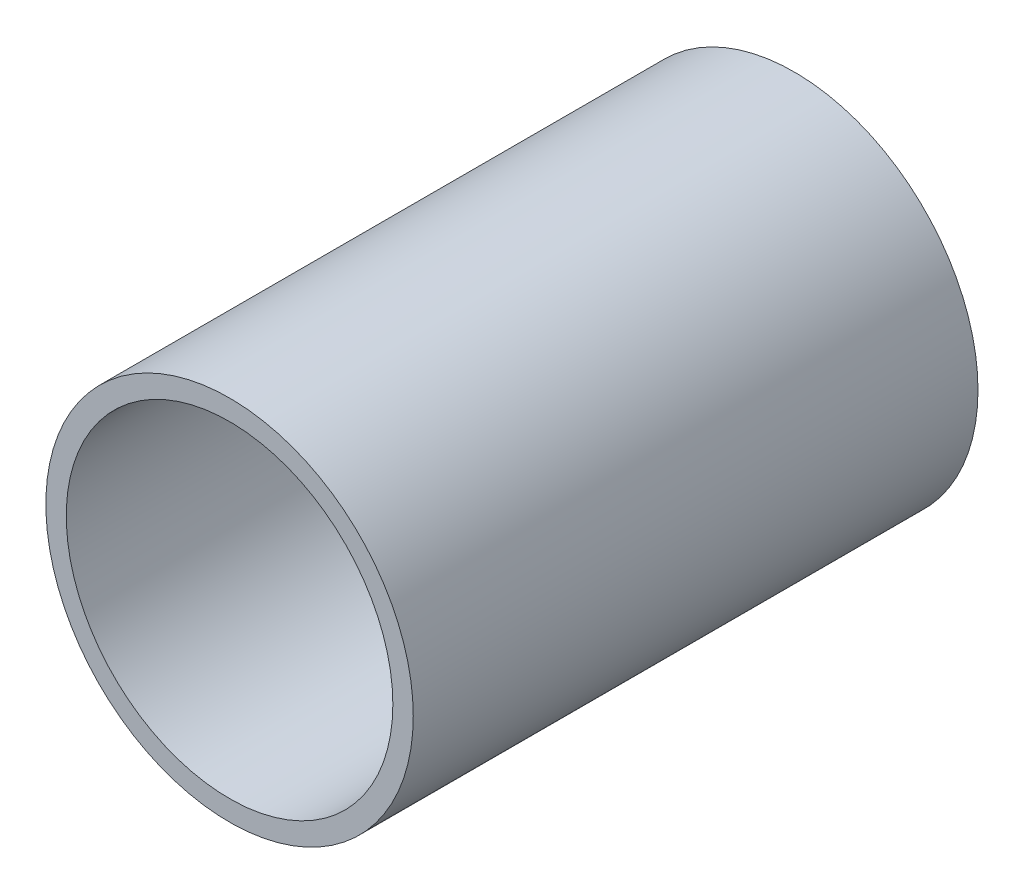
from build123d import *

# Parameters (mm, degrees)
SZKIC1_R                    = 13.5
SZKIC1_R_2                  = 12
DODANIE_WYCI_GNI_CIE1_DEPTH = 41.5


with BuildPart() as part:
    # Szkic1 → Dodanie-wyciągnięcie1 (new body)
    with BuildSketch(Plane.XY):
        Circle(SZKIC1_R)
        Circle(SZKIC1_R_2, mode=Mode.SUBTRACT)
    extrude(amount=DODANIE_WYCI_GNI_CIE1_DEPTH)


solid = part.part
